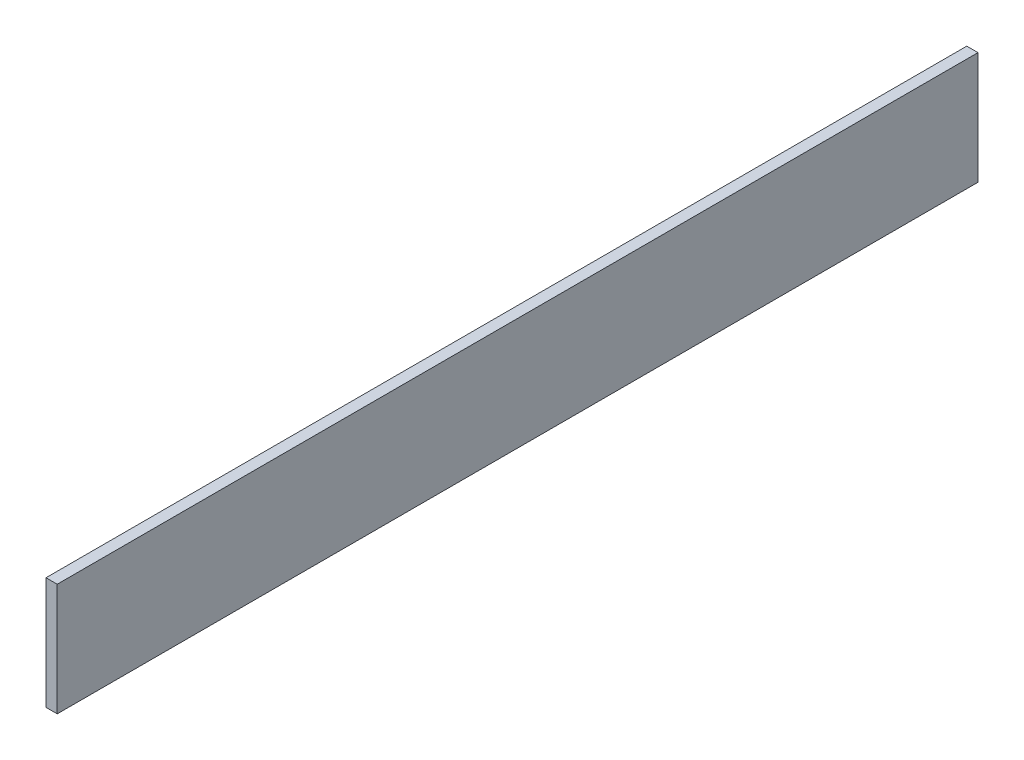
from build123d import *

# Parameters (mm, degrees)
SKETCH1_W           = 5
SKETCH1_H           = 50
BOSS_EXTRUDE1_DEPTH = 410


with BuildPart() as part:
    # Sketch1 → Boss-Extrude1 (new body)
    with BuildSketch(Plane.XY):
        with Locations((-2.5, 25)):
            Rectangle(SKETCH1_W, SKETCH1_H)
    extrude(amount=BOSS_EXTRUDE1_DEPTH)


solid = part.part
